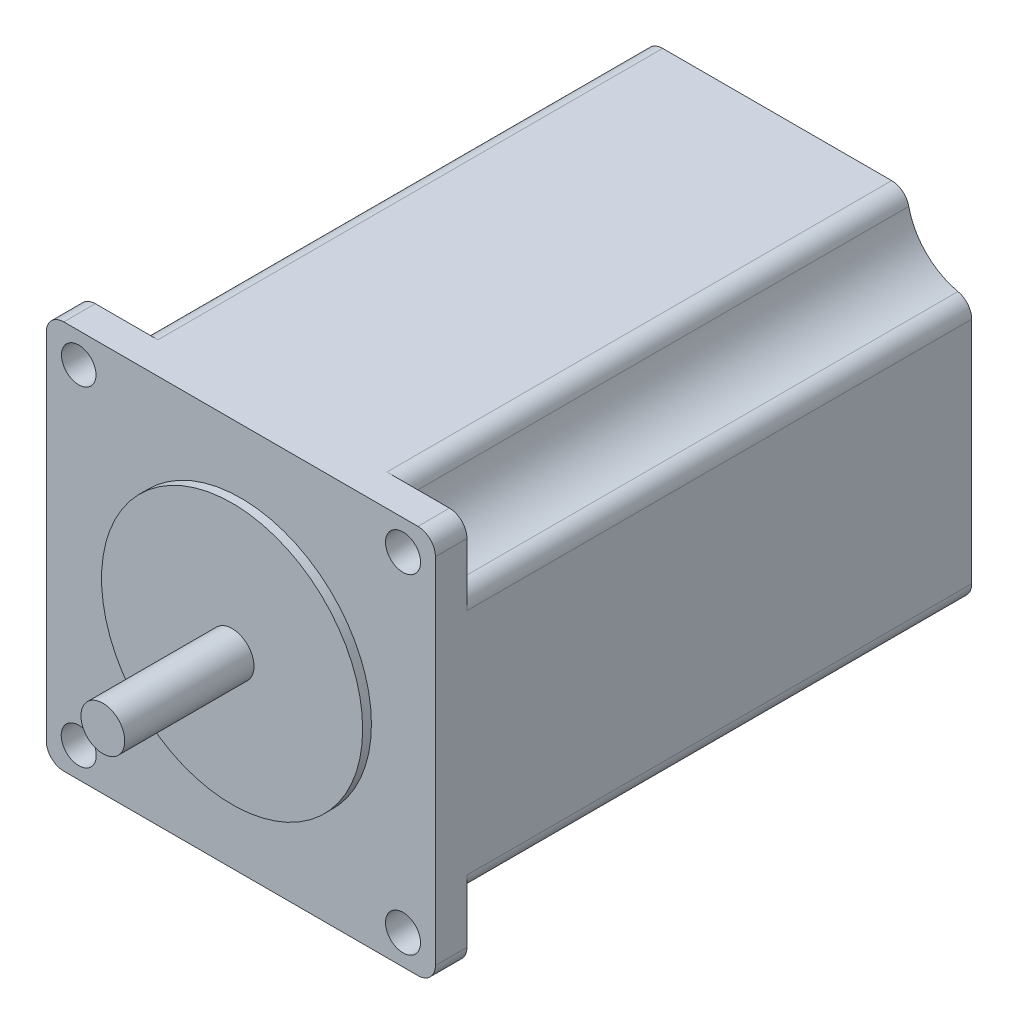
from build123d import *

# Parameters (mm, degrees)
BOSS_EXTRUDE1_DEPTH = 4.572
SKETCH2_R           = 2.5
SKETCH2_R_2         = 2.54
CUT_EXTRUDE1_DEPTH  = 12.7
SKETCH3_R           = 3.175
BOSS_EXTRUDE2_DEPTH = 20
BOSS_EXTRUDE3_DEPTH = 73.152
SKETCH7_R           = 5.08
CUT_EXTRUDE2_DEPTH  = 2.54
SKETCH8_W           = 4.445
SKETCH8_H           = 4.445
BOSS_EXTRUDE4_DEPTH = 2.54
SKETCH9_R           = 18.923
BOSS_EXTRUDE5_DEPTH = 1.27


with BuildPart() as part:
    # Sketch1 → Boss-Extrude1 (new body)
    with BuildSketch(Plane.XY):
        with BuildLine():
            Line((-25.66, 28.194), (25.66, 28.194))
            ThreePointArc((25.66, 28.194), (27.456051224, 27.450051224), (28.2, 25.654))
            Line((28.2, 25.654), (28.2, -25.654))
            ThreePointArc((28.2, -25.654), (27.456051224, -27.450051224), (25.66, -28.194))
            Line((25.66, -28.194), (-25.66, -28.194))
            ThreePointArc((-25.66, -28.194), (-27.456051224, -27.450051224), (-28.2, -25.654))
            Line((-28.2, -25.654), (-28.2, 25.654))
            ThreePointArc((-28.2, 25.654), (-27.456051224, 27.450051224), (-25.66, 28.194))
        make_face()
    extrude(amount=-BOSS_EXTRUDE1_DEPTH)

    # Sketch2 → Cut-Extrude1 (cut)
    with BuildSketch(Plane.XY):
        with Locations((-23.495, 23.876)):
            Circle(SKETCH2_R)
        with Locations((23.505, 23.876)):
            Circle(SKETCH2_R_2)
        with Locations((-23.495, -23.876)):
            Circle(SKETCH2_R_2)
        with Locations((23.505, -23.876)):
            Circle(SKETCH2_R_2)
    extrude(amount=-CUT_EXTRUDE1_DEPTH, mode=Mode.SUBTRACT)

    # Sketch3 → Boss-Extrude2 (add)
    with BuildSketch(Plane.XY):
        Circle(SKETCH3_R)
    extrude(amount=BOSS_EXTRUDE2_DEPTH)

    # Sketch6 → Boss-Extrude3 (add)
    with BuildSketch(Plane(origin=(0, 0, -4.572), x_dir=(-1, 0, 0), z_dir=(0, 0, -1))):
        with BuildLine():
            Line((-16.59544611, 28.194), (16.59544611, 28.194))
            ThreePointArc((16.59544611, 28.194), (18.187513991, 27.633120982), (19.076465755, 26.198188868))
            ThreePointArc((19.076465755, 26.198188868), (21.596845623, 21.593151837), (26.203044563, 19.07489608))
            ThreePointArc((26.203044563, 19.07489608), (27.638753799, 18.186149944), (28.2, 16.59362572))
            Line((28.2, 16.59362572), (28.2, -16.59362572))
            ThreePointArc((28.2, -16.59362572), (27.638442141, -18.186537109), (26.202073469, -19.075108412))
            ThreePointArc((26.202073469, -19.075108412), (21.595673614, -21.592228782), (19.076199379, -26.19734161))
            ThreePointArc((19.076199379, -26.19734161), (18.187399824, -27.632849121), (16.594994048, -28.194))
            Line((16.594994048, -28.194), (-16.594994048, -28.194))
            ThreePointArc((-16.594994048, -28.194), (-18.18696432, -27.633199499), (-19.075960003, -26.198433587))
            ThreePointArc((-19.075960003, -26.198433587), (-21.596706334, -21.593572144), (-26.203011658, -19.07546527))
            ThreePointArc((-26.203011658, -19.07546527), (-27.638743239, -18.186725052), (-28.2, -16.594187708))
            Line((-28.2, -16.594187708), (-28.2, 16.594187708))
            ThreePointArc((-28.2, 16.594187708), (-27.638751536, 18.186714743), (-26.203037512, 19.075459612))
            ThreePointArc((-26.203037512, 19.075459612), (-21.596941467, 21.593557838), (-19.076433541, 26.198335711))
            ThreePointArc((-19.076433541, 26.198335711), (-18.187455421, 27.633168096), (-16.59544611, 28.194))
        make_face()
    extrude(amount=BOSS_EXTRUDE3_DEPTH)

    # Sketch7 → Cut-Extrude2 (cut)
    with BuildSketch(Plane(origin=(0, 0, -77.724), x_dir=(-1, 0, 0), z_dir=(0, 0, -1))):
        Circle(SKETCH7_R)
    extrude(amount=-CUT_EXTRUDE2_DEPTH, mode=Mode.SUBTRACT)

    # Sketch8 → Boss-Extrude4 (add)
    with BuildSketch(Plane(origin=(0, -28.194, 0), x_dir=(-1, 0, 0), z_dir=(0, -1, 0))):
        with Locations((0, 71.6915)):
            Rectangle(SKETCH8_W, SKETCH8_H)
    extrude(amount=BOSS_EXTRUDE4_DEPTH)

    # Sketch9 → Boss-Extrude5 (add)
    with BuildSketch(Plane.XY):
        Circle(SKETCH9_R)
    extrude(amount=BOSS_EXTRUDE5_DEPTH)


solid = part.part
